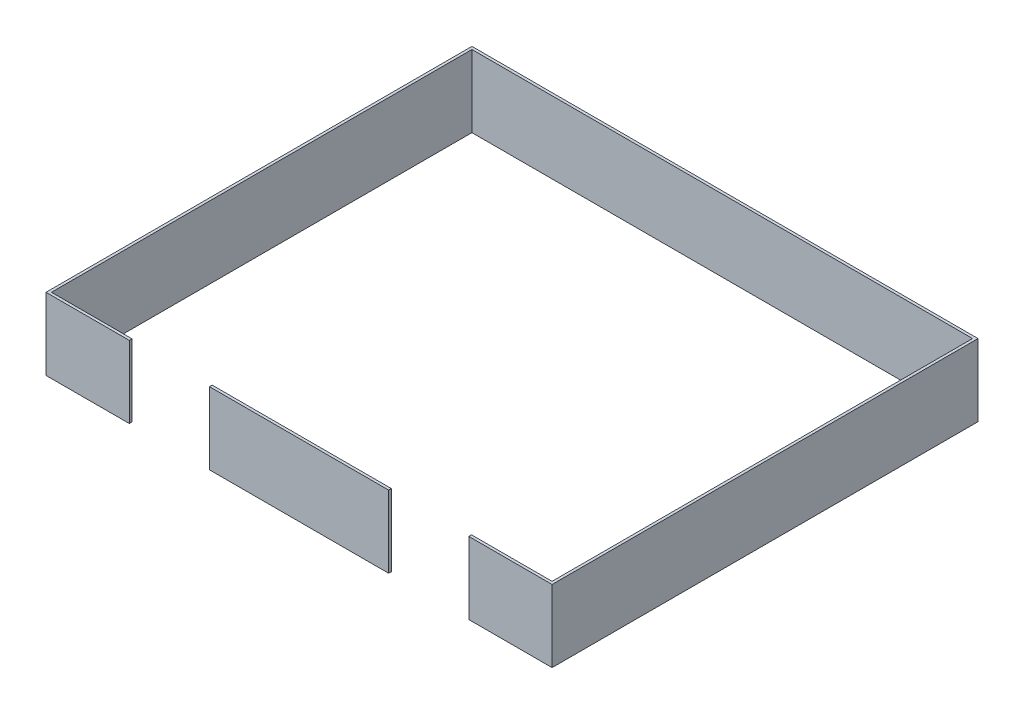
from build123d import *

# Parameters (mm, degrees)
SKETCH1_W           = 7137.4
SKETCH1_H           = 6007.1
SKETCH1_W_2         = 7061.2
SKETCH1_H_2         = 5930.9
BOSS_EXTRUDE1_DEPTH = 1016
SKETCH2_W           = 1130.3
SKETCH2_H           = 38.1
CUT_EXTRUDE1_DEPTH  = 2048.764


with BuildPart() as part:
    # Sketch1 → Boss-Extrude1 (new body)
    with BuildSketch(Plane(origin=(0, 0, 0), x_dir=(1, 0, 0), z_dir=(0, 1, 0))):
        Rectangle(SKETCH1_W, SKETCH1_H)
        Rectangle(SKETCH1_W_2, SKETCH1_H_2, mode=Mode.SUBTRACT)
    extrude(amount=BOSS_EXTRUDE1_DEPTH)

    # Sketch2 → Cut-Extrude1 (cut)
    with BuildSketch(Plane(origin=(0, 1016, 0), x_dir=(1, 0, 0), z_dir=(0, 1, 0))):
        with Locations((-1828.8, -2984.5)):
            Rectangle(SKETCH2_W, SKETCH2_H)
        with Locations((1828.8, -2984.5)):
            Rectangle(SKETCH2_W, SKETCH2_H)
    extrude(amount=-CUT_EXTRUDE1_DEPTH, mode=Mode.SUBTRACT)


solid = part.part
